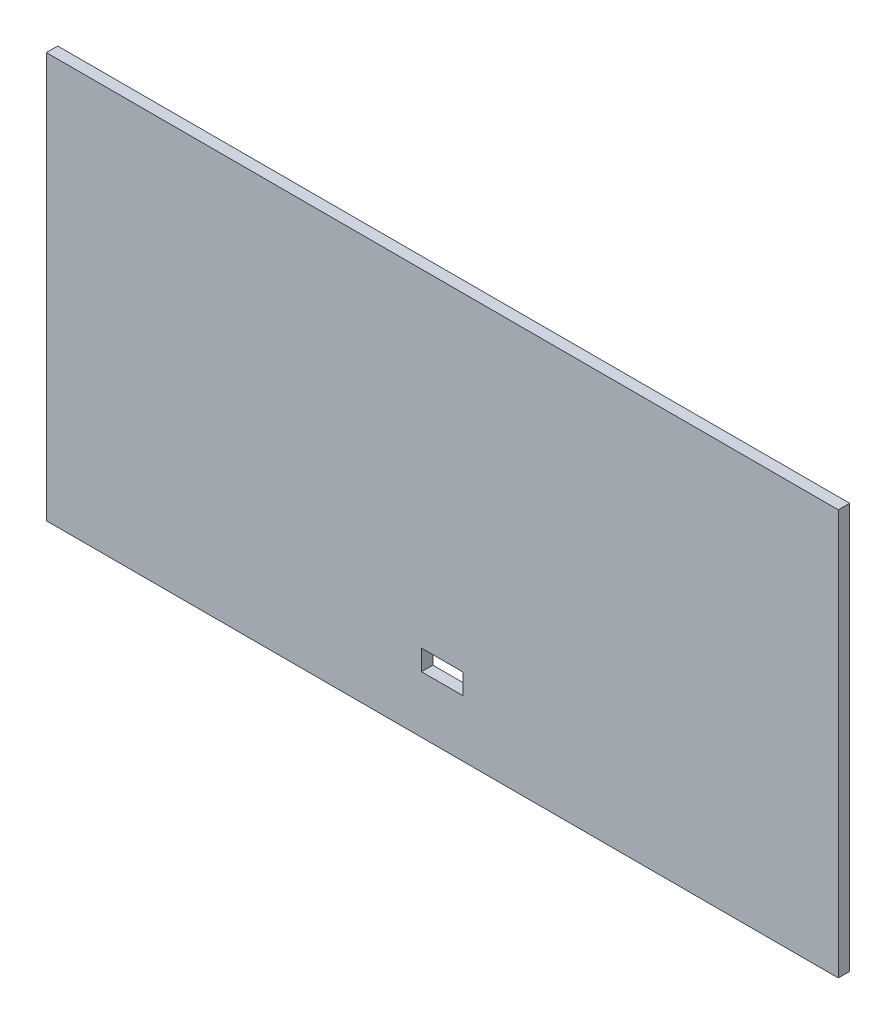
from build123d import *

# Parameters (mm, degrees)
SKETCH1_W           = 209
SKETCH1_H           = 107
SKETCH1_W_2         = 11
SKETCH1_H_2         = 5.4
BOSS_EXTRUDE1_DEPTH = 3


with BuildPart() as part:
    # Sketch1 → Boss-Extrude1 (new body)
    with BuildSketch(Plane.XY):
        Rectangle(SKETCH1_W, SKETCH1_H)
        with Locations((0, -35.8)):
            Rectangle(SKETCH1_W_2, SKETCH1_H_2, mode=Mode.SUBTRACT)
    extrude(amount=BOSS_EXTRUDE1_DEPTH)


solid = part.part
